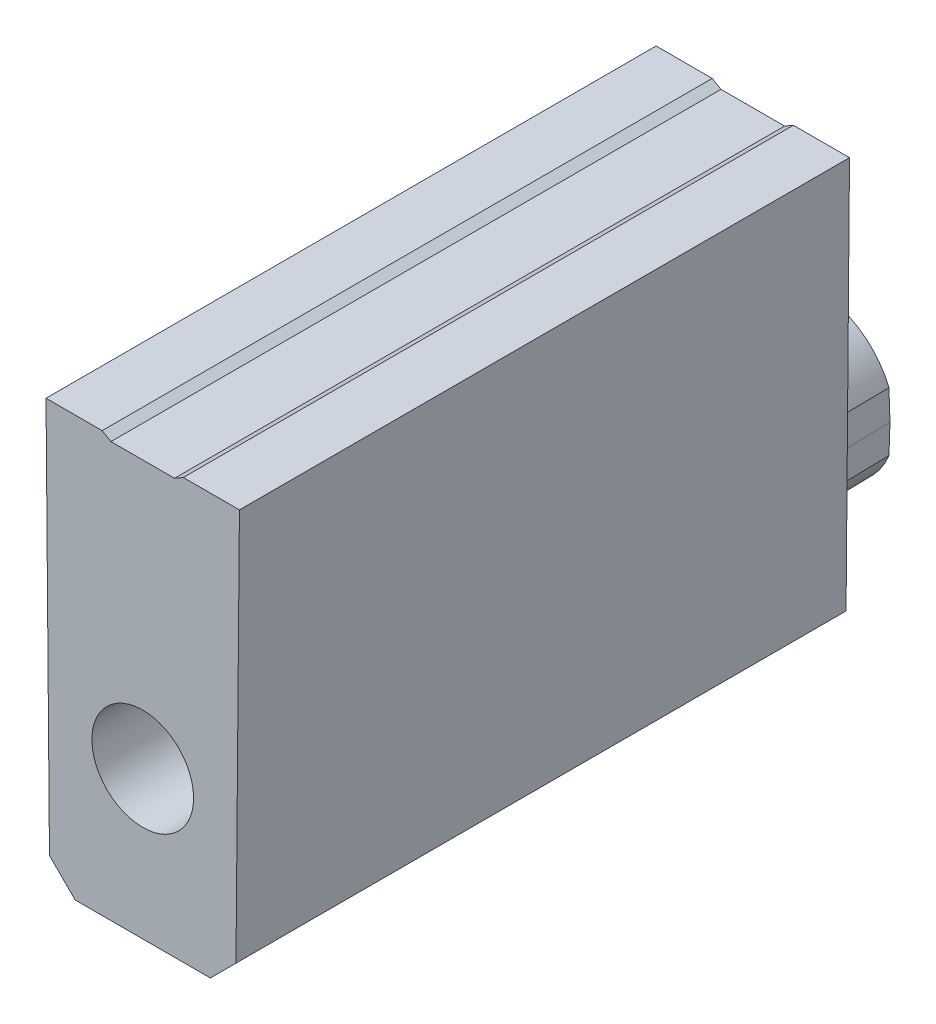
from build123d import *

# Parameters (mm, degrees)
EXTRUDE1_DEPTH     = 15.24
EXTRUDE2_DEPTH     = 1.5875
EXTRUDE2_TAPER     = 1
SKETCH3_R          = 1.27
EXTRUDE3_DEPTH     = 8.89
EXTRUDE3_TAPER     = 0.5
EXTRUDE4_DEPTH     = 16.2400001
CUT_EXTRUDE1_DEPTH = 16.2400001


with BuildPart() as part:
    # Sketch1 → Extrude1 (new body)
    with BuildSketch(Plane.XY):
        Polygon((-2.3241, 0), (2.3241, 0), (2.415646588, 10.4902), (-2.415646588, 10.4902), align=None)
    extrude(amount=EXTRUDE1_DEPTH)

    # Sketch2 → Extrude2 (add)
    with BuildSketch(Plane(origin=(0, 0, 0), x_dir=(-1, 0, 0), z_dir=(0, 0, -1))):
        with BuildLine():
            Line((-1.841041911, 4.423478779), (-1.8669, 3.683))
            Line((-1.8669, 3.683), (-1.841041911, 2.942521221))
            ThreePointArc((-1.841041911, 2.942521221), (0, 1.698625), (1.841041911, 2.942521221))
            Line((1.841041911, 2.942521221), (1.8669, 3.683))
            Line((1.8669, 3.683), (1.841041911, 4.423478779))
            ThreePointArc((1.841041911, 4.423478779), (0, 5.667375), (-1.841041911, 4.423478779))
        make_face()
    extrude(amount=EXTRUDE2_DEPTH, taper=EXTRUDE2_TAPER)

    # Sketch3 → Extrude3 (cut)
    with BuildSketch(Plane.XY.offset(15.24)):
        with Locations((0, 3.683)):
            Circle(SKETCH3_R)
    extrude(amount=-EXTRUDE3_DEPTH, taper=EXTRUDE3_TAPER, mode=Mode.SUBTRACT)

    # Sketch4 → Extrude4 (cut, through all)
    with BuildSketch(Plane(origin=(0, 0, 0), x_dir=(-1, 0, 0), z_dir=(0, 0, -1))):
        Polygon((-1.013720453, 10.4902), (-0.79375, 10.3632), (0.79375, 10.3632), (1.013720453, 10.4902), align=None)
    extrude(amount=-EXTRUDE4_DEPTH, mode=Mode.SUBTRACT)

    # Sketch5 → Cut-Extrude1 (cut, through all)
    with BuildSketch(Plane(origin=(0, 0, 0), x_dir=(-1, 0, 0), z_dir=(0, 0, -1))):
        Polygon((-1.6891, 0), (-2.329690347, 0.640590347), (-2.3241, 0), align=None)
        Polygon((2.3241, 0), (1.6891, 0), (2.329690347, 0.640590347), align=None)
    extrude(amount=-CUT_EXTRUDE1_DEPTH, mode=Mode.SUBTRACT)


solid = part.part
